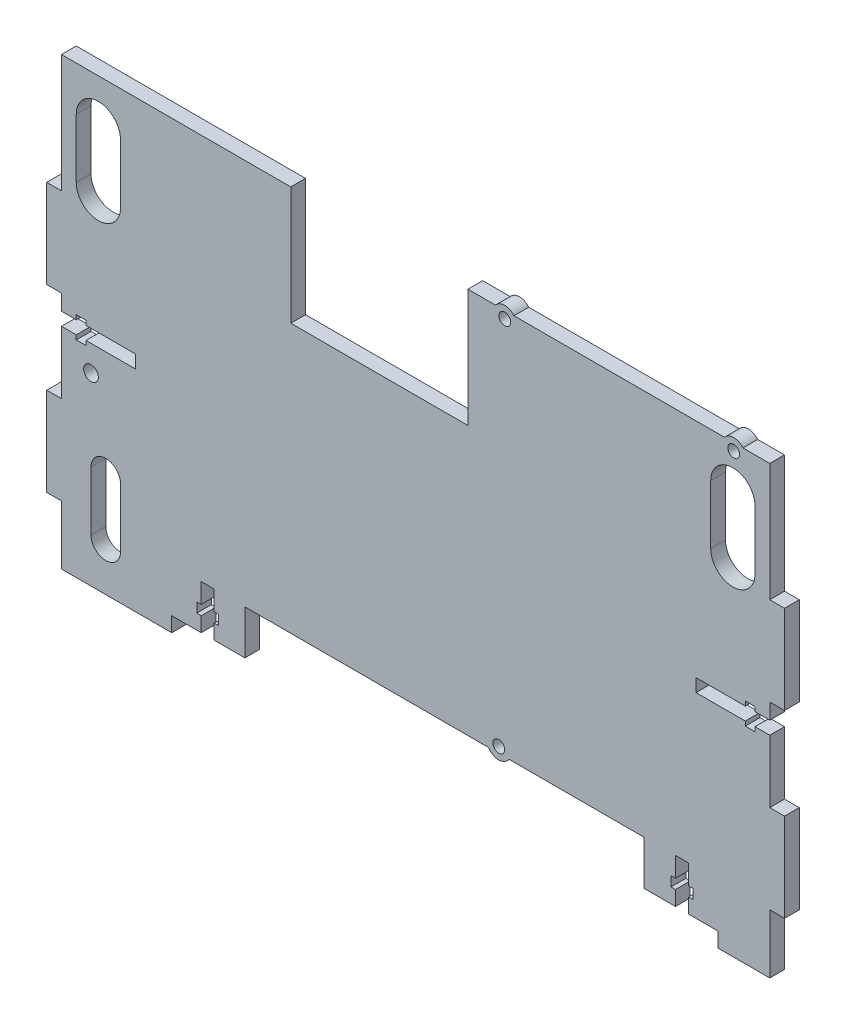
from build123d import *

# Parameters (mm, degrees)
SKETCH1_W           = 240
SKETCH1_H           = 151
BOSS_EXTRUDE1_DEPTH = 5
SKETCH2_W           = 60
SKETCH2_H           = 40
CUT_EXTRUDE1_DEPTH  = 5
SKETCH4_R           = 2
CUT_EXTRUDE3_DEPTH  = 5
SKETCH5_R           = 4
SKETCH5_R_2         = 2
BOSS_EXTRUDE2_DEPTH = 5
CUT_EXTRUDE5_DEPTH  = 5
SKETCH12_R          = 2
CUT_EXTRUDE7_DEPTH  = 5
SKETCH13_R          = 2.5
CUT_EXTRUDE8_DEPTH  = 10
SKETCH16_W          = 5
SKETCH16_H          = 30
BOSS_EXTRUDE5_DEPTH = 5
CUT_EXTRUDE11_DEPTH = 5
SKETCH18_W          = 135.3
SKETCH18_H          = 20
CUT_EXTRUDE13_DEPTH = 10
SKETCH19_R          = 4
SKETCH19_R_2        = 2
BOSS_EXTRUDE6_DEPTH = 5
SKETCH20_W          = 24.8
SKETCH20_H          = 5
CUT_EXTRUDE14_DEPTH = 5
SKETCH21_W          = 25
SKETCH21_H          = 5
CUT_EXTRUDE15_DEPTH = 5
CUT_EXTRUDE16_DEPTH = 5
CUT_EXTRUDE17_DEPTH = 10


with BuildPart() as part:
    # Sketch1 → Boss-Extrude1 (new body)
    with BuildSketch(Plane.XY):
        Rectangle(SKETCH1_W, SKETCH1_H)
    extrude(amount=BOSS_EXTRUDE1_DEPTH)

    # Sketch2 → Cut-Extrude1 (cut)
    with BuildSketch(Plane(origin=(0, 0, 0), x_dir=(-1, 0, 0), z_dir=(0, 0, -1))):
        with Locations((12.301489704, 55.5)):
            Rectangle(SKETCH2_W, SKETCH2_H)
    extrude(amount=-CUT_EXTRUDE1_DEPTH, mode=Mode.SUBTRACT)

    # Sketch4 → Cut-Extrude3 (cut)
    with BuildSketch(Plane(origin=(0, 0, 0), x_dir=(-1, 0, 0), z_dir=(0, 0, -1))):
        with Locations((-107.8, 73)):
            Circle(SKETCH4_R)
        with Locations((-30.2, 73)):
            Circle(SKETCH4_R)
    extrude(amount=-CUT_EXTRUDE3_DEPTH, mode=Mode.SUBTRACT)

    # Sketch5 → Boss-Extrude2 (add)
    with BuildSketch(Plane(origin=(0, 0, 0), x_dir=(-1, 0, 0), z_dir=(0, 0, -1))):
        with Locations((-30.2, 73)):
            Circle(SKETCH5_R)
        with Locations((-30.2, 73)):
            Circle(SKETCH5_R_2, mode=Mode.SUBTRACT)
        with Locations((-107.8, 73)):
            Circle(SKETCH5_R)
        with Locations((-107.8, 73)):
            Circle(SKETCH5_R_2, mode=Mode.SUBTRACT)
    extrude(amount=-BOSS_EXTRUDE2_DEPTH)

    # Sketch8 → Cut-Extrude5 (cut)
    with BuildSketch(Plane(origin=(0, 0, 0), x_dir=(-1, 0, 0), z_dir=(0, 0, -1))):
        with BuildLine():
            Line((100, -60.5), (100, -40.5))
            ThreePointArc((100, -40.5), (105, -35.5), (110, -40.5))
            Line((110, -40.5), (110, -60.5))
            ThreePointArc((110, -60.5), (105, -65.5), (100, -60.5))
        make_face()
    extrude(amount=-CUT_EXTRUDE5_DEPTH, mode=Mode.SUBTRACT)

    # Sketch12 → Cut-Extrude7 (cut)
    with BuildSketch(Plane(origin=(0, 0, 0), x_dir=(-1, 0, 0), z_dir=(0, 0, -1))):
        with Locations((-28.16035742, -53.440416767)):
            Circle(SKETCH12_R)
    extrude(amount=-CUT_EXTRUDE7_DEPTH, mode=Mode.SUBTRACT)

    # Sketch13 → Cut-Extrude8 (cut)
    with BuildSketch(Plane(origin=(0, 0, 0), x_dir=(-1, 0, 0), z_dir=(0, 0, -1))):
        with Locations((110, -13)):
            Circle(SKETCH13_R)
    extrude(amount=-CUT_EXTRUDE8_DEPTH, mode=Mode.SUBTRACT)

    # Sketch16 → Boss-Extrude5 (add)
    with BuildSketch(Plane(origin=(0, 0, 0), x_dir=(-1, 0, 0), z_dir=(0, 0, -1))):
        with Locations((-122.5, 20.5)):
            Rectangle(SKETCH16_W, SKETCH16_H)
        with Locations((-122.5, -40.5)):
            Rectangle(SKETCH16_W, SKETCH16_H)
        with Locations((122.5, -40.5)):
            Rectangle(SKETCH16_W, SKETCH16_H)
        with Locations((122.5, 20.5)):
            Rectangle(SKETCH16_W, SKETCH16_H)
    extrude(amount=-BOSS_EXTRUDE5_DEPTH)

    # Sketch17 → Cut-Extrude11 (cut)
    with BuildSketch(Plane(origin=(0, 0, 0), x_dir=(-1, 0, 0), z_dir=(0, 0, -1))):
        Polygon((-120, 0.154989229), (-115, 0.154989229), (-115, 1.654989229), (-111.7, 1.654989229), (-111.7, 0.154989229), (-95, 0.154989229), (-95, -4.245010771), (-111.7, -4.245010771), (-111.7, -5.745010771), (-115, -5.745010771), (-115, -4.245010771), (-120, -4.245010771), align=None)
        Polygon((120, -4.245010771), (120, 0.154989229), (115, 0.154989229), (115, 1.654989229), (111.7, 1.654989229), (111.7, 0.154989229), (95, 0.154989229), (95, -4.245010771), (111.7, -4.245010771), (111.7, -5.745010771), (115, -5.745010771), (115, -4.245010771), align=None)
    extrude(amount=-CUT_EXTRUDE11_DEPTH, mode=Mode.SUBTRACT)

    # Sketch18 → Cut-Extrude13 (cut)
    with BuildSketch(Plane(origin=(0, 0, 0), x_dir=(-1, 0, 0), z_dir=(0, 0, -1))):
        with Locations((-9.8, -65.5)):
            Rectangle(SKETCH18_W, SKETCH18_H)
    extrude(amount=-CUT_EXTRUDE13_DEPTH, mode=Mode.SUBTRACT)

    # Sketch19 → Boss-Extrude6 (add)
    with BuildSketch(Plane(origin=(0, 0, 0), x_dir=(-1, 0, 0), z_dir=(0, 0, -1))):
        with Locations((-28.16035742, -53.440416767)):
            Circle(SKETCH19_R)
        with Locations((-28.16035742, -53.440416767)):
            Circle(SKETCH19_R_2, mode=Mode.SUBTRACT)
    extrude(amount=-BOSS_EXTRUDE6_DEPTH)

    # Sketch20 → Cut-Extrude14 (cut)
    with BuildSketch(Plane(origin=(0, 0, 0), x_dir=(-1, 0, 0), z_dir=(0, 0, -1))):
        with Locations((70.25, -73)):
            Rectangle(SKETCH20_W, SKETCH20_H)
    extrude(amount=-CUT_EXTRUDE14_DEPTH, mode=Mode.SUBTRACT)

    # Sketch21 → Cut-Extrude15 (cut)
    with BuildSketch(Plane(origin=(0, 0, 0), x_dir=(-1, 0, 0), z_dir=(0, 0, -1))):
        with Locations((-89.95, -73)):
            Rectangle(SKETCH21_W, SKETCH21_H)
    extrude(amount=-CUT_EXTRUDE15_DEPTH, mode=Mode.SUBTRACT)

    # Sketch22 → Cut-Extrude16 (cut)
    with BuildSketch(Plane(origin=(0, 0, 0), x_dir=(-1, 0, 0), z_dir=(0, 0, -1))):
        Polygon((68.25, -55.5), (68.25, -62.2), (66.75, -62.2), (66.75, -65.5), (68.25, -65.5), (68.25, -70.5), (72.65, -70.5), (72.65, -65.5), (74.15, -65.5), (74.15, -62.2), (72.65, -62.2), (72.65, -55.5), align=None)
        Polygon((-92.45, -55.5), (-92.45, -62.2), (-93.95, -62.2), (-93.95, -65.5), (-92.45, -65.5), (-92.45, -70.5), (-88.05, -70.5), (-88.05, -65.5), (-86.55, -65.5), (-86.55, -62.2), (-88.05, -62.2), (-88.05, -55.5), align=None)
    extrude(amount=-CUT_EXTRUDE16_DEPTH, mode=Mode.SUBTRACT)

    # Sketch23 → Cut-Extrude17 (cut)
    with BuildSketch(Plane(origin=(0, 0, 0), x_dir=(-1, 0, 0), z_dir=(0, 0, -1))):
        with BuildLine():
            Line((-100, 60.5), (-100, 40.5))
            ThreePointArc((-100, 40.5), (-107.5, 33), (-115, 40.5))
            Line((-115, 40.5), (-115, 60.5))
            ThreePointArc((-115, 60.5), (-107.5, 68), (-100, 60.5))
        make_face()
        with BuildLine():
            Line((100, 60.5), (100, 40.5))
            ThreePointArc((100, 40.5), (107.5, 33), (115, 40.5))
            Line((115, 40.5), (115, 60.5))
            ThreePointArc((115, 60.5), (107.5, 68), (100, 60.5))
        make_face()
    extrude(amount=-CUT_EXTRUDE17_DEPTH, mode=Mode.SUBTRACT)


solid = part.part
